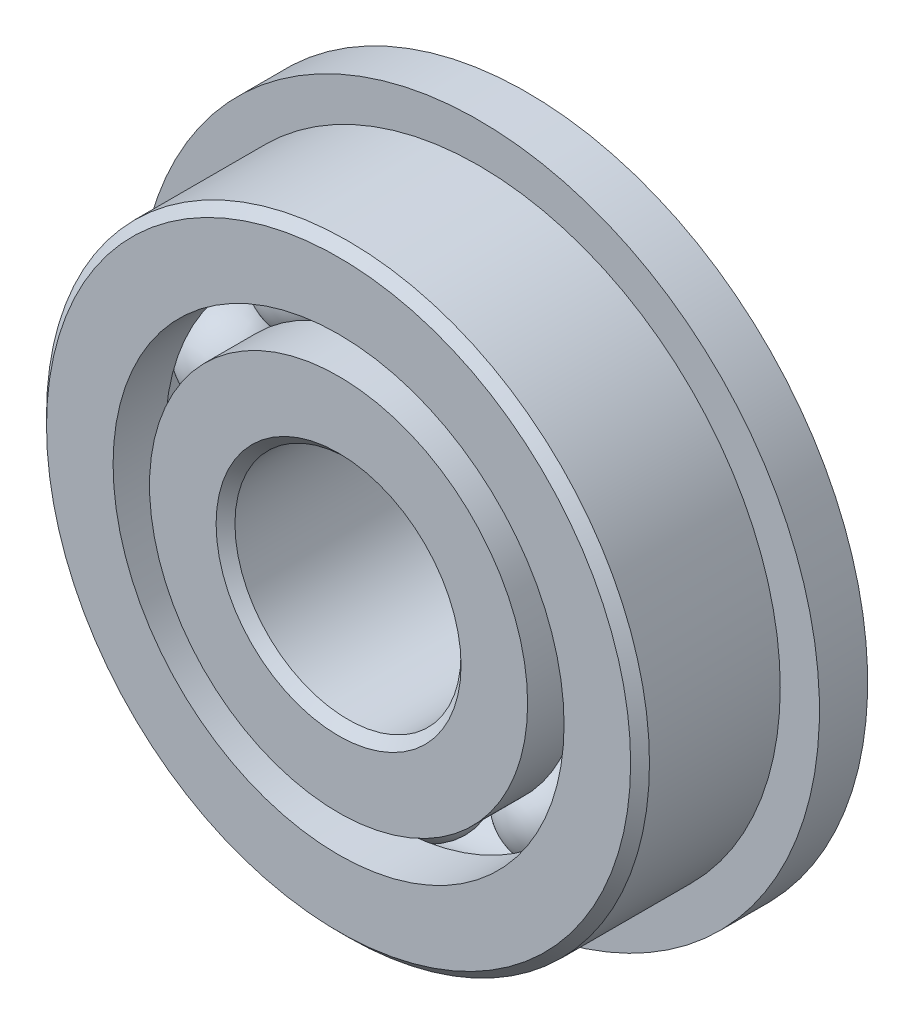
from build123d import *

# Parameters (mm, degrees)
CIRPATTERN1_COUNT = 10
SKETCH6_W         = 1.016
SKETCH6_H         = 2.426083791


with BuildPart() as part:
    # Sketch1 → Revolve1 (revolve)
    with BuildSketch(Plane(origin=(0, 0, 0), x_dir=(0, 0, -1), z_dir=(1, 0, 0))):
        with BuildLine():
            Line((1.7859375, 6.35), (-1.7859375, 6.35))
            Line((-1.7859375, 6.35), (-1.984375, 6.1515625))
            Line((-1.984375, 6.1515625), (-1.984375, 4.749416209))
            Line((-1.984375, 4.749416209), (-0.881944444, 4.749416209))
            ThreePointArc((-0.881944444, 4.749416209), (0, 5.327457467), (0.881944444, 4.749416209))
            Line((0.881944444, 4.749416209), (1.984375, 4.749416209))
            Line((1.984375, 4.749416209), (1.984375, 6.1515625))
            Line((1.984375, 6.1515625), (1.7859375, 6.35))
        make_face()
    revolve(axis=Axis((0, 0, 1.984375), (0, 0, -1)))

    # Sketch6 → Revolve6 (revolve)
    with BuildSketch(Plane(origin=(0, 0, 0), x_dir=(0, 0, -1), z_dir=(1, 0, 0))):
        with Locations((1.476375, 5.962458105)):
            Rectangle(SKETCH6_W, SKETCH6_H)
    revolve(axis=Axis((0, 0, -1.984375), (0, 0, 1)))


with BuildPart() as body_2:
    # Sketch3 → Revolve3 (revolve)
    with BuildSketch(Plane(origin=(0, 0, 0), x_dir=(0, 0, -1), z_dir=(1, 0, 0))):
        with BuildLine():
            Line((-1.984375, 3.981833791), (-0.881944444, 3.981833791))
            ThreePointArc((-0.881944444, 3.981833791), (0, 3.403792533), (0.881944444, 3.981833791))
            Line((0.881944444, 3.981833791), (1.984375, 3.981833791))
            Line((1.984375, 3.981833791), (1.984375, 2.5796875))
            Line((1.984375, 2.5796875), (1.7859375, 2.38125))
            Line((1.7859375, 2.38125), (-1.7859375, 2.38125))
            Line((-1.7859375, 2.38125), (-1.984375, 2.5796875))
            Line((-1.984375, 2.5796875), (-1.984375, 3.981833791))
        make_face()
    revolve(axis=Axis((0, 0, 1.984375), (0, 0, -1)))


with BuildPart() as body_3:
    # Sketch4 → Revolve4 (revolve)
    with BuildSketch(Plane(origin=(0, 0, 0), x_dir=(0, 0, -1), z_dir=(1, 0, 0))):
        with BuildLine():
            Line((-0.961832467, 4.365625), (0.961832467, 4.365625))
            ThreePointArc((0.961832467, 4.365625), (0, 5.327457467), (-0.961832467, 4.365625))
        make_face()
    revolve(axis=Axis((0, 4.365625, 0.961832467), (0, 0, -1)))


with BuildPart() as cirpattern1_1:
    # CirPattern1: pattern copy
    add(body_3.part.rotate(Axis((0, 0, -1.984375), (0, 0, 1)), 1 * 360 / CIRPATTERN1_COUNT))


with BuildPart() as cirpattern1_2:
    # CirPattern1: pattern copy
    add(body_3.part.rotate(Axis((0, 0, -1.984375), (0, 0, 1)), 2 * 360 / CIRPATTERN1_COUNT))


with BuildPart() as cirpattern1_3:
    # CirPattern1: pattern copy
    add(body_3.part.rotate(Axis((0, 0, -1.984375), (0, 0, 1)), 3 * 360 / CIRPATTERN1_COUNT))


with BuildPart() as cirpattern1_4:
    # CirPattern1: pattern copy
    add(body_3.part.rotate(Axis((0, 0, -1.984375), (0, 0, 1)), 4 * 360 / CIRPATTERN1_COUNT))


with BuildPart() as cirpattern1_5:
    # CirPattern1: pattern copy
    add(body_3.part.rotate(Axis((0, 0, -1.984375), (0, 0, 1)), 5 * 360 / CIRPATTERN1_COUNT))


with BuildPart() as cirpattern1_6:
    # CirPattern1: pattern copy
    add(body_3.part.rotate(Axis((0, 0, -1.984375), (0, 0, 1)), 6 * 360 / CIRPATTERN1_COUNT))


with BuildPart() as cirpattern1_7:
    # CirPattern1: pattern copy
    add(body_3.part.rotate(Axis((0, 0, -1.984375), (0, 0, 1)), 7 * 360 / CIRPATTERN1_COUNT))


with BuildPart() as cirpattern1_8:
    # CirPattern1: pattern copy
    add(body_3.part.rotate(Axis((0, 0, -1.984375), (0, 0, 1)), 8 * 360 / CIRPATTERN1_COUNT))


with BuildPart() as cirpattern1_9:
    # CirPattern1: pattern copy
    add(body_3.part.rotate(Axis((0, 0, -1.984375), (0, 0, 1)), 9 * 360 / CIRPATTERN1_COUNT))


solid = Compound([part.part, body_2.part, body_3.part, cirpattern1_1.part, cirpattern1_2.part, cirpattern1_3.part, cirpattern1_4.part, cirpattern1_5.part, cirpattern1_6.part, cirpattern1_7.part, cirpattern1_8.part, cirpattern1_9.part])
